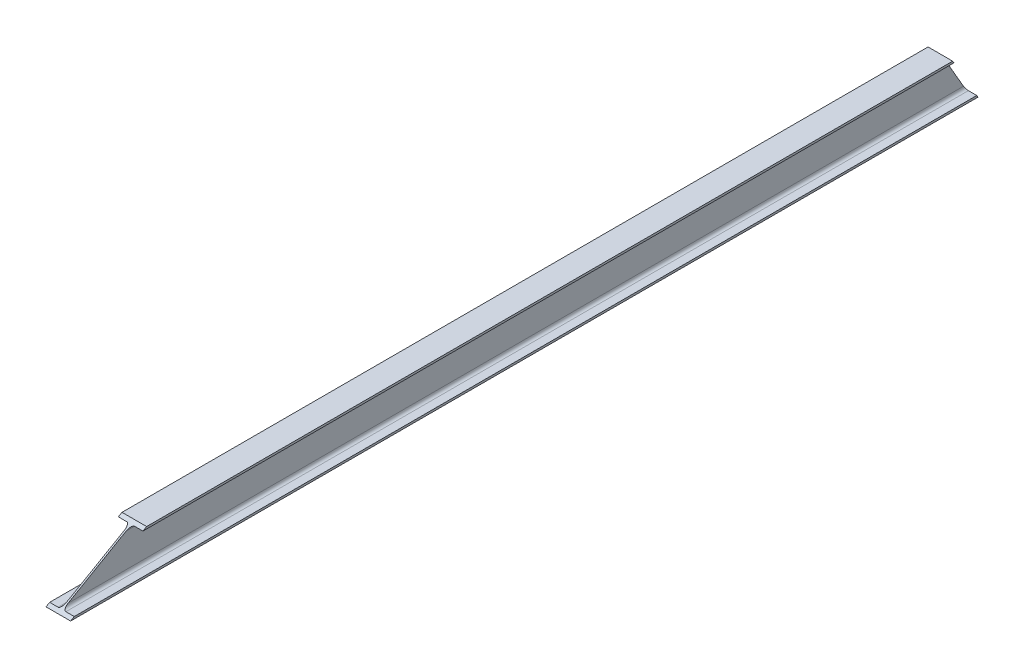
from build123d import *

# Parameters (mm, degrees)
BOSS_EXTRUDE1_DEPTH     = 2032
SKETCH2_W               = 211.702458594
SKETCH2_H               = 483.586926944
CUT_EXTRUDE1_DEPTH      = 50
SKETCH3_W               = 200.611820878
SKETCH3_H               = 857.421683483
CUT_EXTRUDE3_DEPTH      = 85.870489571
CUT_EXTRUDE3_DEPTH_BACK = 2.54


with BuildPart() as part:
    # Sketch1 → Boss-Extrude1 (new body)
    with BuildSketch(Plane.XY):
        with BuildLine():
            Line((-27.5, 49), (27.5, 49))
            Line((27.5, 49), (27.5, 44.3))
            Line((27.5, 44.3), (8.8, 44.3))
            ThreePointArc((8.8, 44.3), (3.850252532, 42.249747468), (1.8, 37.3))
            Line((1.8, 37.3), (1.8, -37.3))
            ThreePointArc((1.8, -37.3), (3.850252532, -42.249747468), (8.8, -44.3))
            Line((8.8, -44.3), (27.5, -44.3))
            Line((27.5, -44.3), (27.5, -49))
            Line((27.5, -49), (-27.5, -49))
            Line((-27.5, -49), (-27.5, -44.3))
            Line((-27.5, -44.3), (-8.8, -44.3))
            ThreePointArc((-8.8, -44.3), (-3.850252532, -42.249747468), (-1.8, -37.3))
            Line((-1.8, -37.3), (-1.8, 37.3))
            ThreePointArc((-1.8, 37.3), (-3.850252532, 42.249747468), (-8.8, 44.3))
            Line((-8.8, 44.3), (-27.5, 44.3))
            Line((-27.5, 44.3), (-27.5, 49))
        make_face()
    extrude(amount=BOSS_EXTRUDE1_DEPTH)

    # Sketch2 → Cut-Extrude1 (cut, through all)
    with BuildSketch(Plane(origin=(0, -12.25, 21.217622393), x_dir=(1, 0, 0), z_dir=(0, -0.5, 0.866025404))):
        with Locations((0, 13.030857736)):
            Rectangle(SKETCH2_W, SKETCH2_H)
    extrude(amount=-CUT_EXTRUDE1_DEPTH, mode=Mode.SUBTRACT)

    # Sketch3 → Cut-Extrude3 (cut, two sides)
    with BuildSketch(Plane(origin=(0, 843.131810245, 486.782377607), x_dir=(1, 0, 0), z_dir=(0, 0.866025404, 0.5))) as cut_extrude3_sk:
        with Locations((6.979656851, -1512.870182956)):
            Rectangle(SKETCH3_W, SKETCH3_H)
    extrude(amount=CUT_EXTRUDE3_DEPTH, mode=Mode.SUBTRACT)
    extrude(cut_extrude3_sk.sketch, amount=-CUT_EXTRUDE3_DEPTH_BACK, mode=Mode.SUBTRACT)


solid = part.part
